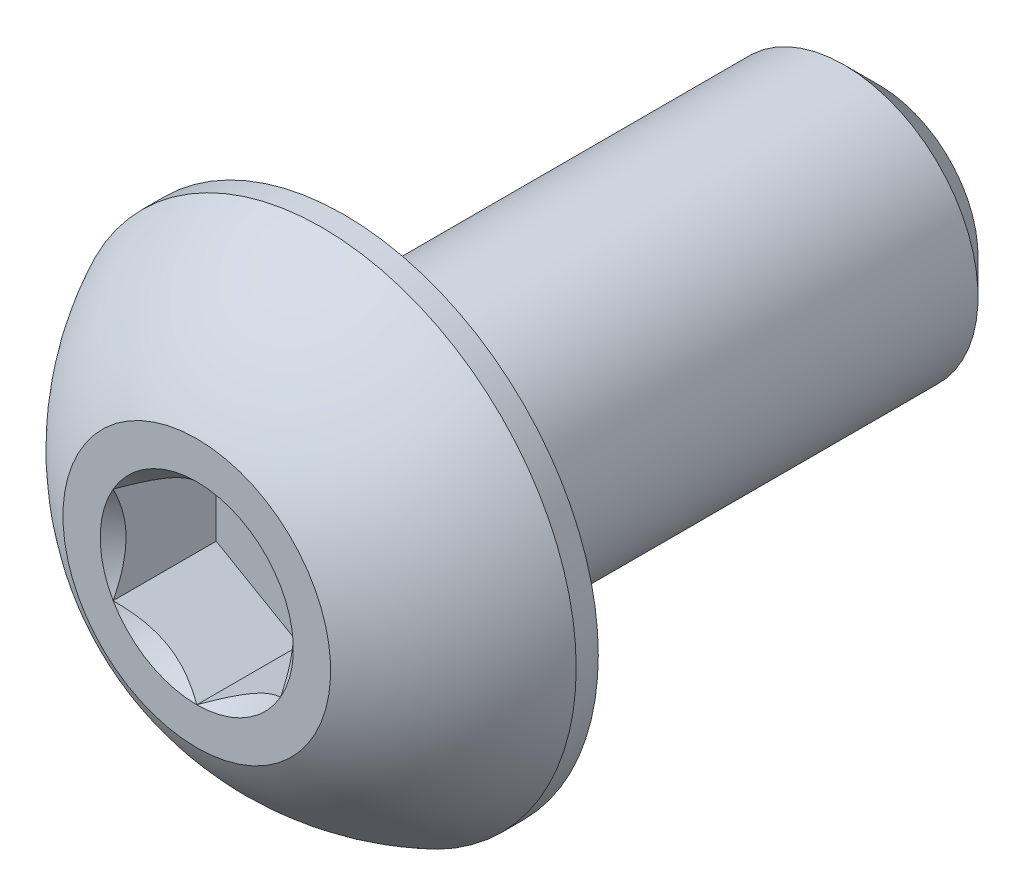
from build123d import *

# Parameters (mm, degrees)
SKETCH1_W          = 8
SKETCH1_H          = 2
CHAMFER1_SIZE      = 0.525
CUT_EXTRUDE2_DEPTH = 1.54


with BuildPart() as part:
    # Sketch1 → Revolve1 (revolve)
    with BuildSketch(Plane(origin=(0, 0, 0), x_dir=(0, 0, -1), z_dir=(1, 0, 0))):
        with Locations((6.2, 1)):
            Rectangle(SKETCH1_W, SKETCH1_H)
    revolve(axis=Axis((0, 0, -10.2), (0, 0, 1)))

    # Chamfer1
    chamfer1_edges = [part.edges().sort_by_distance(p)[0] for p in [
        (0, -2, -10.2),
    ]]
    chamfer(chamfer1_edges, length=CHAMFER1_SIZE)

    # Sketch7 → Revolve2 (revolve)
    with BuildSketch(Plane(origin=(0, 0, 0), x_dir=(0, 0, -1), z_dir=(1, 0, 0))):
        with BuildLine():
            Line((1.87, 3.8), (2.2, 3.8))
            Line((2.2, 3.8), (2.2, 0))
            Line((2.2, 0), (0, 0))
            Line((0, 0), (0, 2))
            ThreePointArc((0, 2), (0.793500147, 3.047002626), (1.87, 3.8))
        make_face()
    revolve(axis=Axis((0, 0, 0), (0, 0, -1)))

    # Sketch5 → Cut-Extrude2 (cut)
    with BuildSketch(Plane.XY):
        Polygon((1.25, -0.721687836), (1.25, 0.721687836), (0, 1.443375673), (-1.25, 0.721687836), (-1.25, -0.721687836), (0, -1.443375673), align=None)
    extrude(amount=-CUT_EXTRUDE2_DEPTH, mode=Mode.SUBTRACT)

    # Cut-Extrude3 cone 1 section (through the dimple's axis) → Cut-Extrude3 (revolve, cut)
    with BuildSketch(Plane(origin=(0, 0, 0), x_dir=(0, -1, 0), z_dir=(1, 0, 0))):
        Polygon((0, 0), (1.443375673, 0), (0, 1.443375673), align=None)
    revolve(axis=Axis((0, 0, 0), (0, 0, -1)), mode=Mode.SUBTRACT)


solid = part.part
